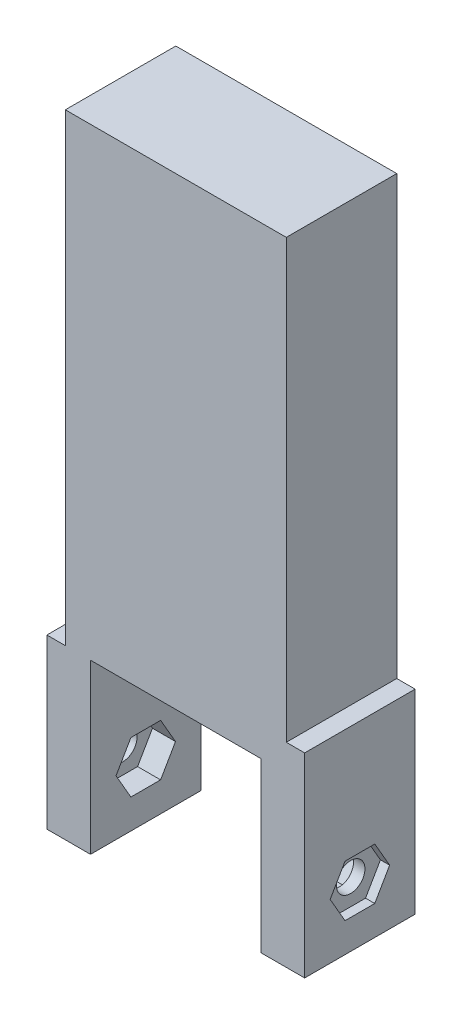
from build123d import *

# Parameters (mm, degrees)
EXTRUDE_1_DEPTH      = 12
CUT_EXTRUDE_12_DEPTH = 1
CUT_EXTRUDE_13_DEPTH = 1
CUT_EXTRUDE_14_DEPTH = 2.5
CUT_EXTRUDE_16_DEPTH = 2.5
SKETCH_26_R          = 1.55
CUT_EXTRUDE_17_DEPTH = 28


with BuildPart() as part:
    # 스케치1 → 보스-돌출1 (new body)
    with BuildSketch(Plane.XY):
        Polygon((-11.994395335, 44.774969809), (-11.994395335, -5.635030191), (-13.999795062, -5.635030191), (-13.999795062, -23.903190191), (-9.261084312, -23.903190191), (-9.261084312, -5.635030191), (9.261494188, -5.637088258), (9.261494188, -23.903190191), (14.000204938, -23.903190191), (14.000204938, -2.727088258), (12.005604665, -2.727088258), (12.005604665, 44.774969809), align=None)
    extrude(amount=EXTRUDE_1_DEPTH)

    # 스케치20 → 컷-돌출12 (cut)
    with BuildSketch(Plane(origin=(14.000204938, 0, 0), x_dir=(0, 0, -1), z_dir=(1, 0, 0))):
        Polygon((-4.384999641, -20.702278724), (-7.614999641, -20.702278724), (-9.228415158, -17.900454093), (-7.61341897, -15.106842492), (-4.380259285, -15.106842492), (-2.768420518, -17.905928971), align=None)
    extrude(amount=-CUT_EXTRUDE_12_DEPTH, mode=Mode.SUBTRACT)

    # 스케치21 → 컷-돌출13 (cut)
    with BuildSketch(Plane.ZY.offset(13.999795062)):
        Polygon((7.611047299, -20.705014823), (4.381047299, -20.705014823), (2.767631782, -17.903190191), (4.38262797, -15.109578591), (7.615787655, -15.109578591), (9.227626422, -17.90866507), align=None)
    extrude(amount=-CUT_EXTRUDE_13_DEPTH, mode=Mode.SUBTRACT)

    # 스케치22 → 컷-돌출14 (cut)
    with BuildSketch(Plane.ZY.offset(-9.261494188)):
        Polygon((7.615000359, -20.702278724), (4.385000359, -20.702278724), (2.771584842, -17.900454093), (4.38658103, -15.106842492), (7.619740715, -15.106842492), (9.231579482, -17.905928971), align=None)
    extrude(amount=-CUT_EXTRUDE_14_DEPTH, mode=Mode.SUBTRACT)

    # 스케치25 → 컷-돌출16 (cut)
    with BuildSketch(Plane(origin=(-9.261084312, 0, 0), x_dir=(0, 0, -1), z_dir=(1, 0, 0))):
        Polygon((-4.384999641, -20.702278724), (-7.614999641, -20.702278724), (-9.228415158, -17.900454093), (-7.61341897, -15.106842492), (-4.380259285, -15.106842492), (-2.768420518, -17.905928971), align=None)
    extrude(amount=-CUT_EXTRUDE_16_DEPTH, mode=Mode.SUBTRACT)

    # 스케치26 → 컷-돌출17 (cut, through all)
    with BuildSketch(Plane.ZY.offset(12.999795062)):
        with Locations((6, -17.903190191)):
            Circle(SKETCH_26_R)
    extrude(amount=-CUT_EXTRUDE_17_DEPTH, mode=Mode.SUBTRACT)


solid = part.part
